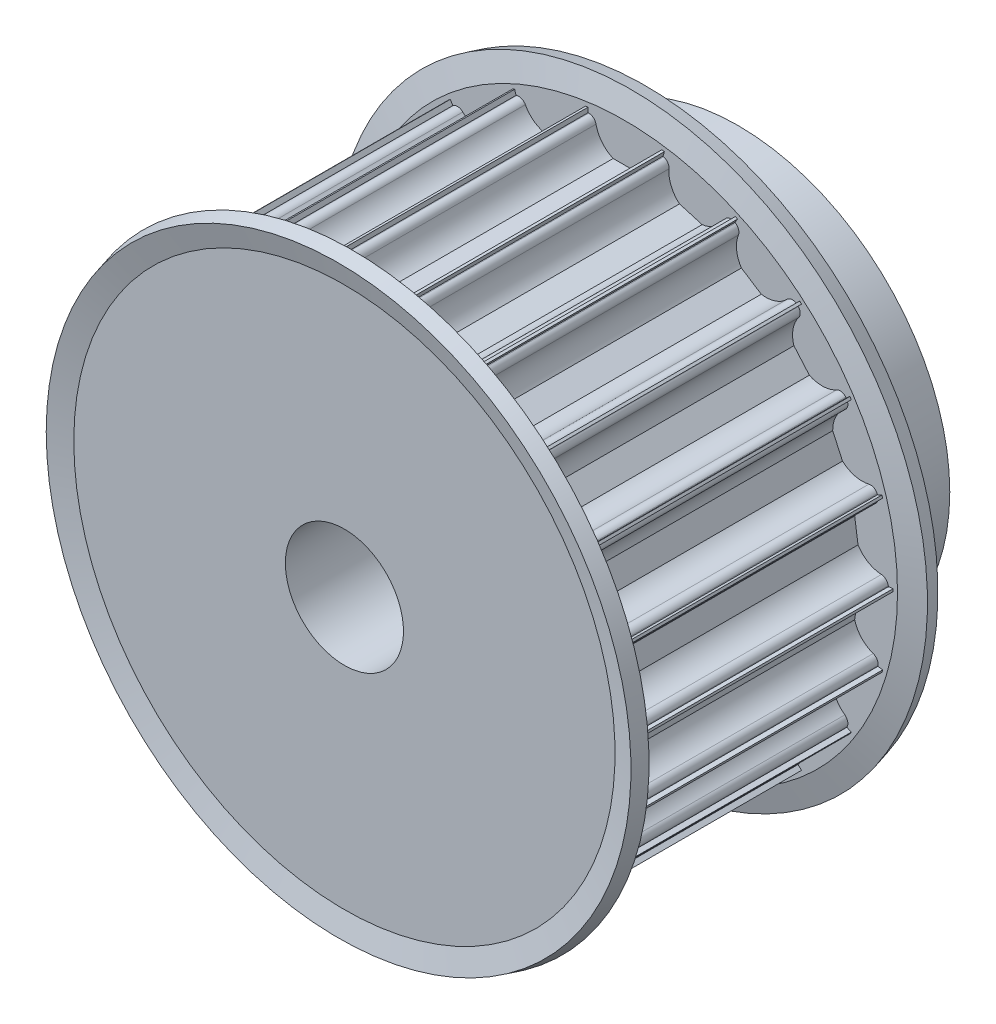
from build123d import *

# Parameters (mm, degrees)
CORTAR_EXTRUIR1_DEPTH = 41
MATRIZC1_COUNT        = 22


with BuildPart() as part:
    # Croquis1 → Revolución1 (revolve)
    with BuildSketch(Plane(origin=(0, 0, 0), x_dir=(0, 0, -1), z_dir=(1, 0, 0))):
        Polygon((0, 6), (0, 27.25), (30, 27.25), (30, 21.5), (40, 21.5), (40, 6), align=None)
    revolve(axis=Axis((0, 0, -88.99), (0, 0, 1)))

    # Croquis2 → Cortar-Extruir1 (cut, through all)
    with BuildSketch(Plane.XY):
        with BuildLine():
            Line((3.674234614, 26.5), (3.75, 26.5))
            Line((3.75, 26.5), (3.75, 28.5))
            Line((3.75, 28.5), (-3.75, 28.5))
            Line((-3.75, 28.5), (-3.75, 26.5))
            Line((-3.75, 26.5), (-3.674234614, 26.5))
            ThreePointArc((-3.674234614, 26.5), (-3.199892965, 26.330947502), (-2.939387691, 25.9))
            ThreePointArc((-2.939387691, 25.9), (-2.331759211, 24.612435701), (-1.198957881, 23.75))
            Line((-1.198957881, 23.75), (1.198957881, 23.75))
            ThreePointArc((1.198957881, 23.75), (2.331759211, 24.612435701), (2.939387691, 25.9))
            ThreePointArc((2.939387691, 25.9), (3.199892965, 26.330947502), (3.674234614, 26.5))
        make_face()
    cortar_extruir1 = extrude(amount=-CORTAR_EXTRUIR1_DEPTH, mode=Mode.SUBTRACT)

    # MatrizC1: Cortar-Extruir1 ×22 about axis
    matrizc1_axis = Axis((0, 0, 0), (0, 0, 1))
    for i in range(1, MATRIZC1_COUNT):
        add(cortar_extruir1.rotate(matrizc1_axis, i * 360 / MATRIZC1_COUNT), mode=Mode.SUBTRACT)

    # Croquis4 → Revolución2 (revolve)
    with BuildSketch(Plane(origin=(0, 0, 0), x_dir=(0, 0, -1), z_dir=(1, 0, 0))):
        Polygon((0, 27.493260406), (0, 22.690739153), (1.5, 22.690739153), (1.5, 27.690739153), (0.856921938, 30.090739153), (-0.591966801, 29.702510585), align=None)
        Polygon((30.591966801, 29.702510585), (29.143078062, 30.090739153), (28.5, 27.690739153), (28.5, 22.690739153), (30, 22.690739153), (30, 27.493260406), align=None)
    revolve(axis=Axis((0, 0, -88.99), (0, 0, 1)))


solid = part.part
